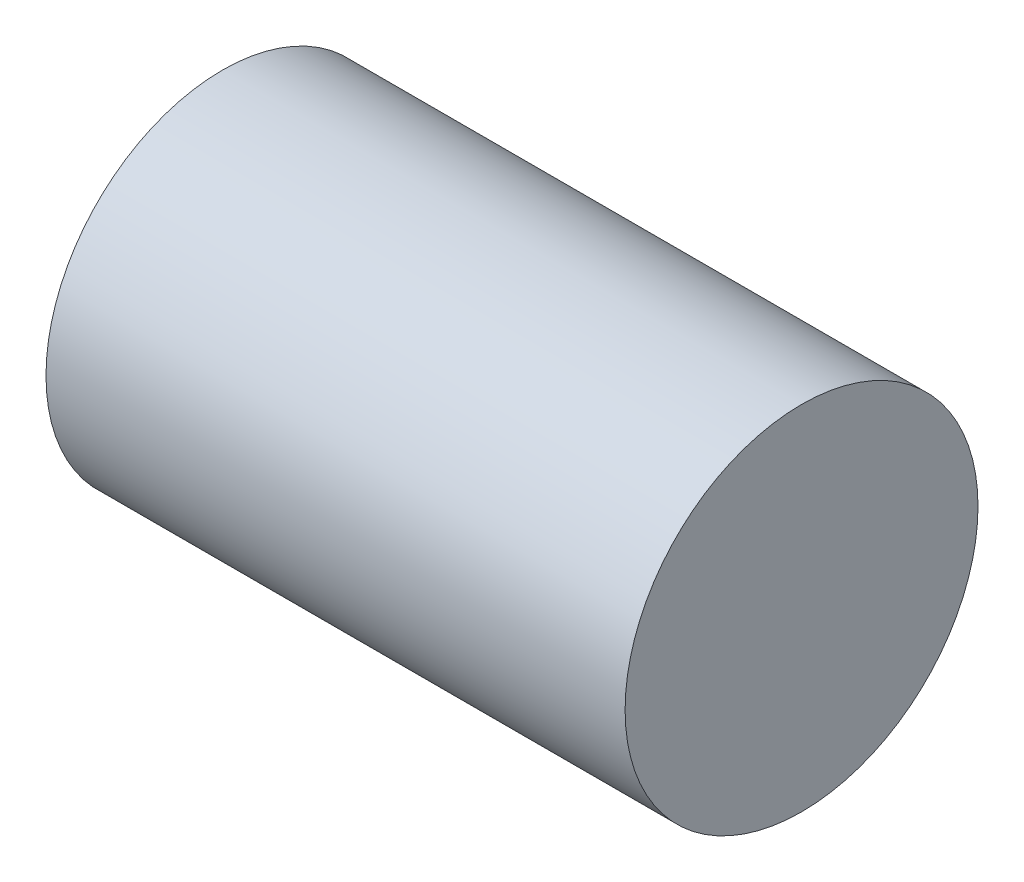
from build123d import *

# Parameters (mm, degrees)
SKETCH2_R           = 19.5
BOSS_EXTRUDE1_DEPTH = 64
SKETCH3_R           = 8
CUT_EXTRUDE1_DEPTH  = 50


with BuildPart() as part:
    # Sketch2 → Boss-Extrude1 (new body)
    with BuildSketch(Plane(origin=(0, 0, 0), x_dir=(0, 0, -1), z_dir=(1, 0, 0))):
        Circle(SKETCH2_R)
    extrude(amount=BOSS_EXTRUDE1_DEPTH)

    # Sketch3 → Cut-Extrude1 (cut)
    with BuildSketch(Plane.ZY):
        Circle(SKETCH3_R)
    extrude(amount=-CUT_EXTRUDE1_DEPTH, mode=Mode.SUBTRACT)


solid = part.part
